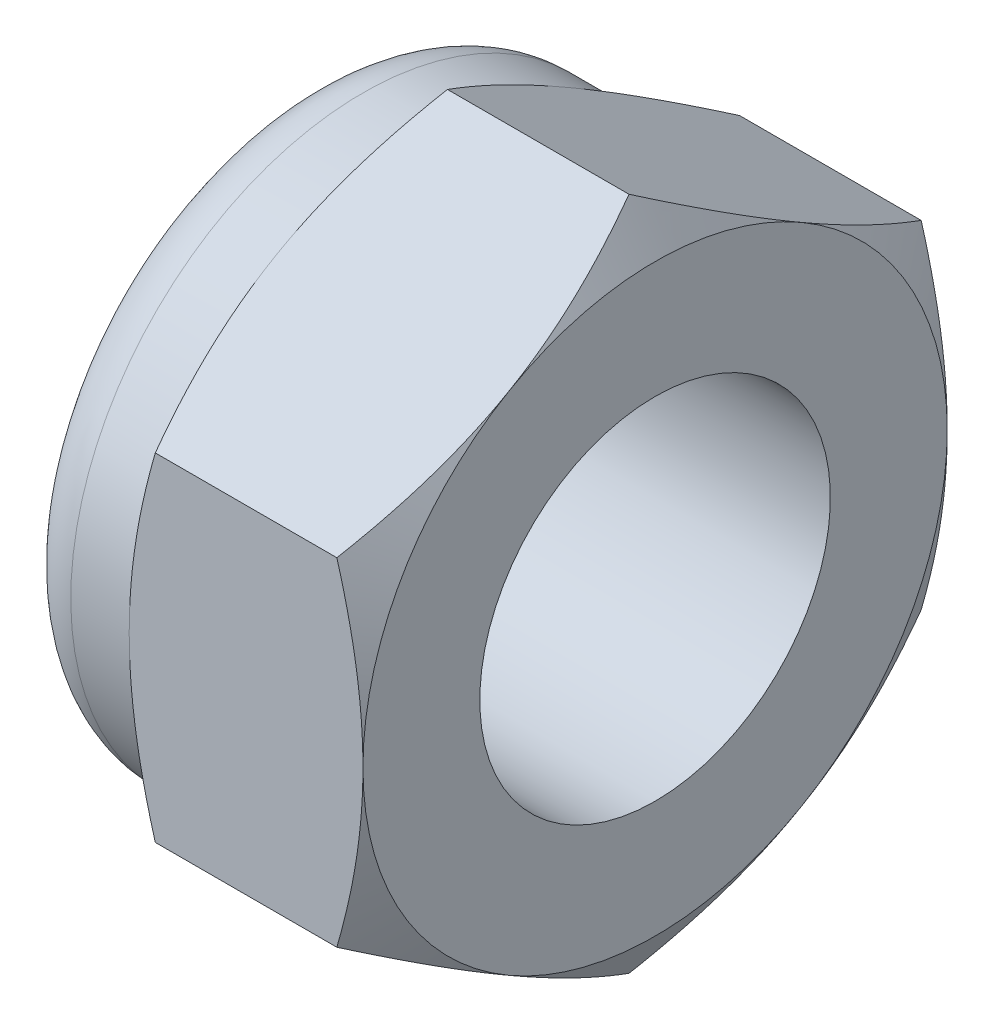
from build123d import *

# Parameters (mm, degrees)
BOSS_EXTRUDE1_DEPTH = 6
SKETCH2_W           = 6
SKETCH2_H           = 3


with BuildPart() as part:
    # Sketch1 → Boss-Extrude1 (new body)
    with BuildSketch(Plane(origin=(0, 0, 0), x_dir=(0, 0, -1), z_dir=(1, 0, 0))):
        Polygon((0, 5.773502692), (-5, 2.886751346), (-5, -2.886751346), (0, -5.773502692), (5, -2.886751346), (5, 2.886751346), align=None)
    extrude(amount=-BOSS_EXTRUDE1_DEPTH)

    # Sketch2 → Cut-Revolve4 (revolve, cut)
    with BuildSketch(Plane.XY):
        Polygon((0, 5), (-0.446581987, 5.773502692), (0, 5.773502692), align=None)
        with BuildLine():
            Line((-3.553418013, 5.773502692), (-4, 5))
            Line((-4, 5), (-5, 5))
            ThreePointArc((-5, 5), (-5.707106781, 4.707106781), (-6, 4))
            Line((-6, 4), (-6.773502692, 4))
            Line((-6.773502692, 4), (-6.773502692, 5.773502692))
            Line((-6.773502692, 5.773502692), (-3.553418013, 5.773502692))
        make_face()
        with Locations((-3, 1.5)):
            Rectangle(SKETCH2_W, SKETCH2_H)
    revolve(axis=Axis((-8.121993413, 0, 0), (1, 0, 0)), mode=Mode.SUBTRACT)


solid = part.part
